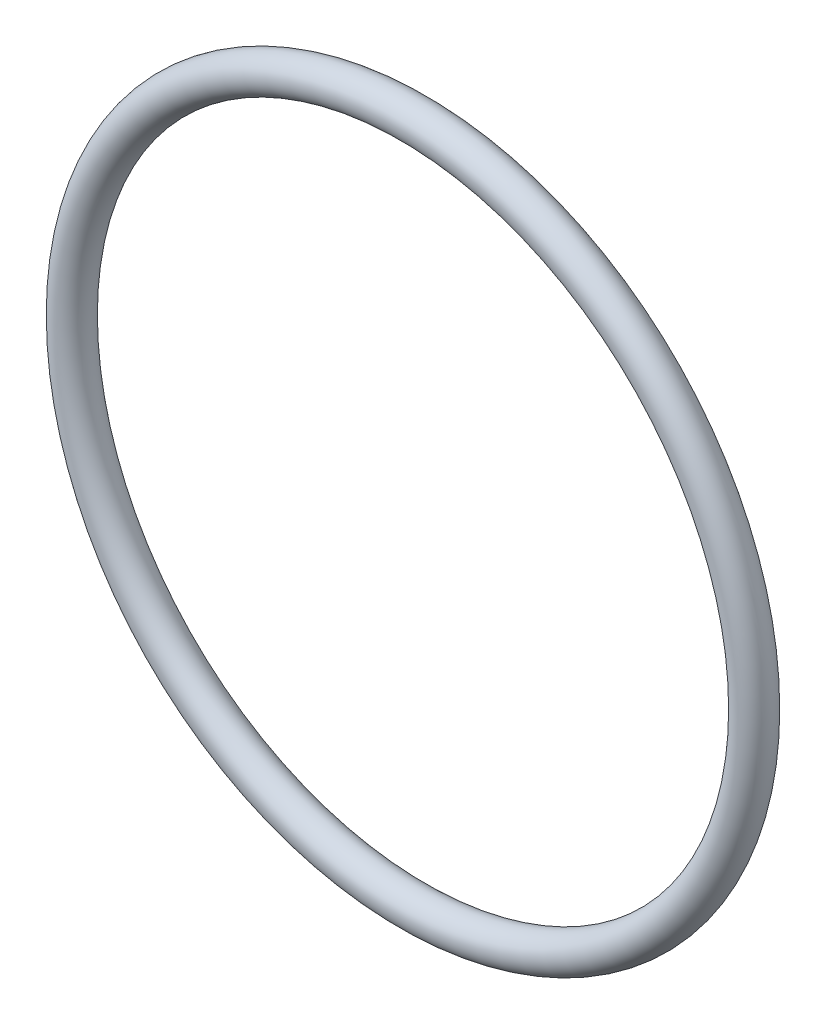
from build123d import *

# Parameters (mm, degrees)
SKETCH1_R = 1.7653


with BuildPart() as part:
    # Sketch1 → Revolve1 (revolve)
    with BuildSketch(Plane(origin=(0, 0, 0), x_dir=(0, -1, 0), z_dir=(1, 0, 0))):
        with Locations((33.3121, 0)):
            Circle(SKETCH1_R)
    revolve(axis=Axis((0, 0, 1.7653), (0, 0, -1)))


solid = part.part
